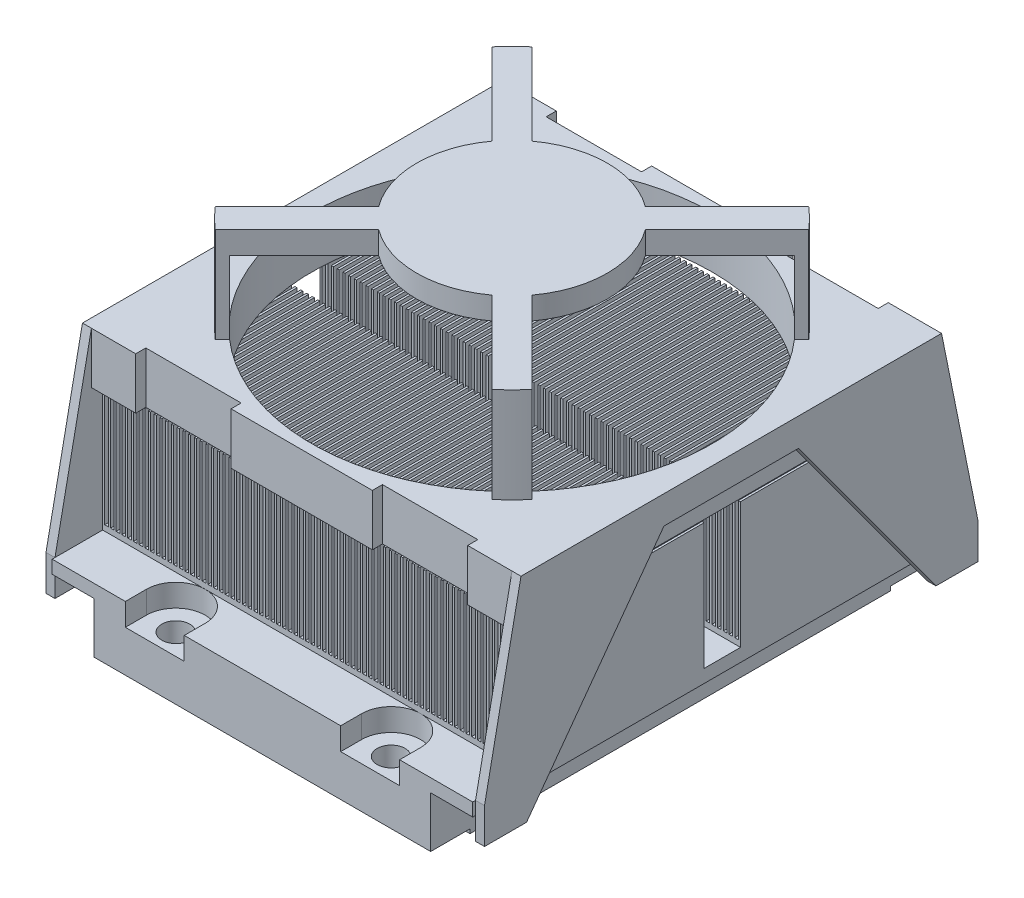
from build123d import *

# Parameters (mm, degrees)
SKETCH1_W                = 75
SKETCH1_H                = 89
BOSS_EXTRUDE1_DEPTH      = 12.15
SKETCH2_W                = 7.5
SKETCH2_H                = 89
CUT_EXTRUDE1_DEPTH       = 9.82
SKETCH3_W                = 60
SKETCH3_H                = 7
CUT_EXTRUDE2_DEPTH       = 0.75
SKETCH4_R                = 2.5
CUT_EXTRUDE3_DEPTH       = 60.299747048
CUT_EXTRUDE4_DEPTH       = 4
SKETCH6_W                = 75
SKETCH6_H                = 32.25
BOSS_EXTRUDE2_DEPTH      = 1
SKETCH7_W                = 0.375
SKETCH7_H                = 32.25
BOSS_EXTRUDE3_DEPTH      = 21.5
LPATTERN2_COUNT          = 74
LPATTERN2_PITCH          = 1.022260274
MIRROR1_COPY_1_SKETCH_W  = 0.375
MIRROR1_COPY_1_SKETCH_H  = 32.25
MIRROR1_COPY_1_DEPTH     = 21.5
MIRROR1_COPY_2_SKETCH_W  = 0.375
MIRROR1_COPY_2_SKETCH_H  = 32.25
MIRROR1_COPY_2_DEPTH     = 21.5
MIRROR1_COPY_3_SKETCH_W  = 0.375
MIRROR1_COPY_3_SKETCH_H  = 32.25
MIRROR1_COPY_3_DEPTH     = 21.5
MIRROR1_COPY_4_SKETCH_W  = 0.375
MIRROR1_COPY_4_SKETCH_H  = 32.25
MIRROR1_COPY_4_DEPTH     = 21.5
MIRROR1_COPY_5_SKETCH_W  = 0.375
MIRROR1_COPY_5_SKETCH_H  = 32.25
MIRROR1_COPY_5_DEPTH     = 21.5
MIRROR1_COPY_6_SKETCH_W  = 0.375
MIRROR1_COPY_6_SKETCH_H  = 32.25
MIRROR1_COPY_6_DEPTH     = 21.5
MIRROR1_COPY_7_SKETCH_W  = 0.375
MIRROR1_COPY_7_SKETCH_H  = 32.25
MIRROR1_COPY_7_DEPTH     = 21.5
MIRROR1_COPY_8_SKETCH_W  = 0.375
MIRROR1_COPY_8_SKETCH_H  = 32.25
MIRROR1_COPY_8_DEPTH     = 21.5
MIRROR1_COPY_9_SKETCH_W  = 0.375
MIRROR1_COPY_9_SKETCH_H  = 32.25
MIRROR1_COPY_9_DEPTH     = 21.5
MIRROR1_COPY_10_SKETCH_W = 0.375
MIRROR1_COPY_10_SKETCH_H = 32.25
MIRROR1_COPY_10_DEPTH    = 21.5
MIRROR1_COPY_11_SKETCH_W = 0.375
MIRROR1_COPY_11_SKETCH_H = 32.25
MIRROR1_COPY_11_DEPTH    = 21.5
MIRROR1_COPY_12_SKETCH_W = 0.375
MIRROR1_COPY_12_SKETCH_H = 32.25
MIRROR1_COPY_12_DEPTH    = 21.5
MIRROR1_COPY_13_SKETCH_W = 0.375
MIRROR1_COPY_13_SKETCH_H = 32.25
MIRROR1_COPY_13_DEPTH    = 21.5
MIRROR1_COPY_14_SKETCH_W = 0.375
MIRROR1_COPY_14_SKETCH_H = 32.25
MIRROR1_COPY_14_DEPTH    = 21.5
MIRROR1_COPY_15_SKETCH_W = 0.375
MIRROR1_COPY_15_SKETCH_H = 32.25
MIRROR1_COPY_15_DEPTH    = 21.5
MIRROR1_COPY_16_SKETCH_W = 0.375
MIRROR1_COPY_16_SKETCH_H = 32.25
MIRROR1_COPY_16_DEPTH    = 21.5
MIRROR1_COPY_17_SKETCH_W = 0.375
MIRROR1_COPY_17_SKETCH_H = 32.25
MIRROR1_COPY_17_DEPTH    = 21.5
MIRROR1_COPY_18_SKETCH_W = 0.375
MIRROR1_COPY_18_SKETCH_H = 32.25
MIRROR1_COPY_18_DEPTH    = 21.5
MIRROR1_COPY_19_SKETCH_W = 0.375
MIRROR1_COPY_19_SKETCH_H = 32.25
MIRROR1_COPY_19_DEPTH    = 21.5
MIRROR1_COPY_20_SKETCH_W = 0.375
MIRROR1_COPY_20_SKETCH_H = 32.25
MIRROR1_COPY_20_DEPTH    = 21.5
MIRROR1_COPY_21_SKETCH_W = 0.375
MIRROR1_COPY_21_SKETCH_H = 32.25
MIRROR1_COPY_21_DEPTH    = 21.5
MIRROR1_COPY_22_SKETCH_W = 0.375
MIRROR1_COPY_22_SKETCH_H = 32.25
MIRROR1_COPY_22_DEPTH    = 21.5
MIRROR1_COPY_23_SKETCH_W = 0.375
MIRROR1_COPY_23_SKETCH_H = 32.25
MIRROR1_COPY_23_DEPTH    = 21.5
MIRROR1_COPY_24_SKETCH_W = 0.375
MIRROR1_COPY_24_SKETCH_H = 32.25
MIRROR1_COPY_24_DEPTH    = 21.5
MIRROR1_COPY_25_SKETCH_W = 0.375
MIRROR1_COPY_25_SKETCH_H = 32.25
MIRROR1_COPY_25_DEPTH    = 21.5
MIRROR1_COPY_26_SKETCH_W = 0.375
MIRROR1_COPY_26_SKETCH_H = 32.25
MIRROR1_COPY_26_DEPTH    = 21.5
MIRROR1_COPY_27_SKETCH_W = 0.375
MIRROR1_COPY_27_SKETCH_H = 32.25
MIRROR1_COPY_27_DEPTH    = 21.5
MIRROR1_COPY_28_SKETCH_W = 0.375
MIRROR1_COPY_28_SKETCH_H = 32.25
MIRROR1_COPY_28_DEPTH    = 21.5
MIRROR1_COPY_29_SKETCH_W = 0.375
MIRROR1_COPY_29_SKETCH_H = 32.25
MIRROR1_COPY_29_DEPTH    = 21.5
MIRROR1_COPY_30_SKETCH_W = 0.375
MIRROR1_COPY_30_SKETCH_H = 32.25
MIRROR1_COPY_30_DEPTH    = 21.5
MIRROR1_COPY_31_SKETCH_W = 0.375
MIRROR1_COPY_31_SKETCH_H = 32.25
MIRROR1_COPY_31_DEPTH    = 21.5
MIRROR1_COPY_32_SKETCH_W = 0.375
MIRROR1_COPY_32_SKETCH_H = 32.25
MIRROR1_COPY_32_DEPTH    = 21.5
MIRROR1_COPY_33_SKETCH_W = 0.375
MIRROR1_COPY_33_SKETCH_H = 32.25
MIRROR1_COPY_33_DEPTH    = 21.5
MIRROR1_COPY_34_SKETCH_W = 0.375
MIRROR1_COPY_34_SKETCH_H = 32.25
MIRROR1_COPY_34_DEPTH    = 21.5
MIRROR1_COPY_35_SKETCH_W = 0.375
MIRROR1_COPY_35_SKETCH_H = 32.25
MIRROR1_COPY_35_DEPTH    = 21.5
MIRROR1_COPY_36_SKETCH_W = 0.375
MIRROR1_COPY_36_SKETCH_H = 32.25
MIRROR1_COPY_36_DEPTH    = 21.5
MIRROR1_COPY_37_SKETCH_W = 0.375
MIRROR1_COPY_37_SKETCH_H = 32.25
MIRROR1_COPY_37_DEPTH    = 21.5
MIRROR1_COPY_38_SKETCH_W = 0.375
MIRROR1_COPY_38_SKETCH_H = 32.25
MIRROR1_COPY_38_DEPTH    = 21.5
MIRROR1_COPY_39_SKETCH_W = 0.375
MIRROR1_COPY_39_SKETCH_H = 32.25
MIRROR1_COPY_39_DEPTH    = 21.5
MIRROR1_COPY_40_SKETCH_W = 0.375
MIRROR1_COPY_40_SKETCH_H = 32.25
MIRROR1_COPY_40_DEPTH    = 21.5
MIRROR1_COPY_41_SKETCH_W = 0.375
MIRROR1_COPY_41_SKETCH_H = 32.25
MIRROR1_COPY_41_DEPTH    = 21.5
MIRROR1_COPY_42_SKETCH_W = 0.375
MIRROR1_COPY_42_SKETCH_H = 32.25
MIRROR1_COPY_42_DEPTH    = 21.5
MIRROR1_COPY_43_SKETCH_W = 0.375
MIRROR1_COPY_43_SKETCH_H = 32.25
MIRROR1_COPY_43_DEPTH    = 21.5
MIRROR1_COPY_44_SKETCH_W = 0.375
MIRROR1_COPY_44_SKETCH_H = 32.25
MIRROR1_COPY_44_DEPTH    = 21.5
MIRROR1_COPY_45_SKETCH_W = 0.375
MIRROR1_COPY_45_SKETCH_H = 32.25
MIRROR1_COPY_45_DEPTH    = 21.5
MIRROR1_COPY_46_SKETCH_W = 0.375
MIRROR1_COPY_46_SKETCH_H = 32.25
MIRROR1_COPY_46_DEPTH    = 21.5
MIRROR1_COPY_47_SKETCH_W = 0.375
MIRROR1_COPY_47_SKETCH_H = 32.25
MIRROR1_COPY_47_DEPTH    = 21.5
MIRROR1_COPY_48_SKETCH_W = 0.375
MIRROR1_COPY_48_SKETCH_H = 32.25
MIRROR1_COPY_48_DEPTH    = 21.5
MIRROR1_COPY_49_SKETCH_W = 0.375
MIRROR1_COPY_49_SKETCH_H = 32.25
MIRROR1_COPY_49_DEPTH    = 21.5
MIRROR1_COPY_50_SKETCH_W = 0.375
MIRROR1_COPY_50_SKETCH_H = 32.25
MIRROR1_COPY_50_DEPTH    = 21.5
MIRROR1_COPY_51_SKETCH_W = 0.375
MIRROR1_COPY_51_SKETCH_H = 32.25
MIRROR1_COPY_51_DEPTH    = 21.5
MIRROR1_COPY_52_SKETCH_W = 0.375
MIRROR1_COPY_52_SKETCH_H = 32.25
MIRROR1_COPY_52_DEPTH    = 21.5
MIRROR1_COPY_53_SKETCH_W = 0.375
MIRROR1_COPY_53_SKETCH_H = 32.25
MIRROR1_COPY_53_DEPTH    = 21.5
MIRROR1_COPY_54_SKETCH_W = 0.375
MIRROR1_COPY_54_SKETCH_H = 32.25
MIRROR1_COPY_54_DEPTH    = 21.5
MIRROR1_COPY_55_SKETCH_W = 0.375
MIRROR1_COPY_55_SKETCH_H = 32.25
MIRROR1_COPY_55_DEPTH    = 21.5
MIRROR1_COPY_56_SKETCH_W = 0.375
MIRROR1_COPY_56_SKETCH_H = 32.25
MIRROR1_COPY_56_DEPTH    = 21.5
MIRROR1_COPY_57_SKETCH_W = 0.375
MIRROR1_COPY_57_SKETCH_H = 32.25
MIRROR1_COPY_57_DEPTH    = 21.5
MIRROR1_COPY_58_SKETCH_W = 0.375
MIRROR1_COPY_58_SKETCH_H = 32.25
MIRROR1_COPY_58_DEPTH    = 21.5
MIRROR1_COPY_59_SKETCH_W = 0.375
MIRROR1_COPY_59_SKETCH_H = 32.25
MIRROR1_COPY_59_DEPTH    = 21.5
MIRROR1_COPY_60_SKETCH_W = 0.375
MIRROR1_COPY_60_SKETCH_H = 32.25
MIRROR1_COPY_60_DEPTH    = 21.5
MIRROR1_COPY_61_SKETCH_W = 0.375
MIRROR1_COPY_61_SKETCH_H = 32.25
MIRROR1_COPY_61_DEPTH    = 21.5
MIRROR1_COPY_62_SKETCH_W = 0.375
MIRROR1_COPY_62_SKETCH_H = 32.25
MIRROR1_COPY_62_DEPTH    = 21.5
MIRROR1_COPY_63_SKETCH_W = 0.375
MIRROR1_COPY_63_SKETCH_H = 32.25
MIRROR1_COPY_63_DEPTH    = 21.5
MIRROR1_COPY_64_SKETCH_W = 0.375
MIRROR1_COPY_64_SKETCH_H = 32.25
MIRROR1_COPY_64_DEPTH    = 21.5
MIRROR1_COPY_65_SKETCH_W = 0.375
MIRROR1_COPY_65_SKETCH_H = 32.25
MIRROR1_COPY_65_DEPTH    = 21.5
MIRROR1_COPY_66_SKETCH_W = 0.375
MIRROR1_COPY_66_SKETCH_H = 32.25
MIRROR1_COPY_66_DEPTH    = 21.5
MIRROR1_COPY_67_SKETCH_W = 0.375
MIRROR1_COPY_67_SKETCH_H = 32.25
MIRROR1_COPY_67_DEPTH    = 21.5
MIRROR1_COPY_68_SKETCH_W = 0.375
MIRROR1_COPY_68_SKETCH_H = 32.25
MIRROR1_COPY_68_DEPTH    = 21.5
MIRROR1_COPY_69_SKETCH_W = 0.375
MIRROR1_COPY_69_SKETCH_H = 32.25
MIRROR1_COPY_69_DEPTH    = 21.5
MIRROR1_COPY_70_SKETCH_W = 0.375
MIRROR1_COPY_70_SKETCH_H = 32.25
MIRROR1_COPY_70_DEPTH    = 21.5
MIRROR1_COPY_71_SKETCH_W = 0.375
MIRROR1_COPY_71_SKETCH_H = 32.25
MIRROR1_COPY_71_DEPTH    = 21.5
MIRROR1_COPY_72_SKETCH_W = 0.375
MIRROR1_COPY_72_SKETCH_H = 32.25
MIRROR1_COPY_72_DEPTH    = 21.5
MIRROR1_COPY_73_SKETCH_W = 0.375
MIRROR1_COPY_73_SKETCH_H = 32.25
MIRROR1_COPY_73_DEPTH    = 21.5
BOSS_EXTRUDE4_DEPTH      = 1.6
BOSS_EXTRUDE5_DEPTH      = 9.17
SKETCH10_R               = 37.5
BOSS_EXTRUDE6_DEPTH      = 17
SKETCH11_R               = 35.7
CUT_EXTRUDE5_DEPTH       = 22.17
CUT_EXTRUDE6_START       = -17
CUT_EXTRUDE6_DEPTH       = 17


with BuildPart() as part:
    # Sketch1 → Boss-Extrude1 (new body)
    with BuildSketch(Plane(origin=(0, 0, 0), x_dir=(1, 0, 0), z_dir=(0, 1, 0))):
        Rectangle(SKETCH1_W, SKETCH1_H)
    extrude(amount=BOSS_EXTRUDE1_DEPTH)

    # Sketch2 → Cut-Extrude1 (cut)
    with BuildSketch(Plane.XZ):
        with Locations((-33.75, 0)):
            Rectangle(SKETCH2_W, SKETCH2_H)
        with Locations((33.75, 0)):
            Rectangle(SKETCH2_W, SKETCH2_H)
    extrude(amount=-CUT_EXTRUDE1_DEPTH, mode=Mode.SUBTRACT)

    # Sketch3 → Cut-Extrude2 (cut)
    with BuildSketch(Plane.XZ):
        with Locations((0, 41)):
            Rectangle(SKETCH3_W, SKETCH3_H)
        with Locations((0, -41)):
            Rectangle(SKETCH3_W, SKETCH3_H)
    extrude(amount=-CUT_EXTRUDE2_DEPTH, mode=Mode.SUBTRACT)

    # Sketch4 → Cut-Extrude3 (cut, through all)
    with BuildSketch(Plane.XZ.offset(-0.75)):
        with Locations(Location((-19.2, 40.75, 0), (0, 0, 270))):
            Circle(SKETCH4_R)
        with Locations(Location((19.2, 40.75, 0), (0, 0, 270))):
            Circle(SKETCH4_R)
        with Locations(Location((19.2, -40.75, 0), (0, 0, 90))):
            Circle(SKETCH4_R)
        with Locations(Location((-19.2, -40.75, 0), (0, 0, 90))):
            Circle(SKETCH4_R)
    extrude(amount=-CUT_EXTRUDE3_DEPTH, mode=Mode.SUBTRACT)

    # Sketch5 → Cut-Extrude4 (cut)
    with BuildSketch(Plane(origin=(0, 12.15, 0), x_dir=(1, 0, 0), z_dir=(0, 1, 0))):
        with BuildLine():
            Line((-24.45, 40.75), (-24.45, 44.5))
            Line((-24.45, 44.5), (-13.95, 44.5))
            Line((-13.95, 44.5), (-13.95, 40.75))
            ThreePointArc((-13.95, 40.75), (-19.2, 35.5), (-24.45, 40.75))
        make_face()
        with BuildLine():
            Line((24.45, 40.75), (24.45, 44.5))
            Line((24.45, 44.5), (13.95, 44.5))
            Line((13.95, 44.5), (13.95, 40.75))
            ThreePointArc((13.95, 40.75), (19.2, 35.5), (24.45, 40.75))
        make_face()
        with BuildLine():
            Line((13.95, -40.75), (13.95, -44.5))
            Line((13.95, -44.5), (24.45, -44.5))
            Line((24.45, -44.5), (24.45, -40.75))
            ThreePointArc((24.45, -40.75), (19.2, -35.5), (13.95, -40.75))
        make_face()
        with BuildLine():
            Line((-24.45, -40.75), (-24.45, -44.5))
            Line((-24.45, -44.5), (-13.95, -44.5))
            Line((-13.95, -44.5), (-13.95, -40.75))
            ThreePointArc((-13.95, -40.75), (-19.2, -35.5), (-24.45, -40.75))
        make_face()
    extrude(amount=-CUT_EXTRUDE4_DEPTH, mode=Mode.SUBTRACT)

    # Sketch6 → Boss-Extrude2 (add)
    with BuildSketch(Plane(origin=(0, 12.15, 0), x_dir=(1, 0, 0), z_dir=(0, 1, 0))):
        with Locations((0, 19.375)):
            Rectangle(SKETCH6_W, SKETCH6_H)
    boss_extrude2 = extrude(amount=BOSS_EXTRUDE2_DEPTH)

    # Sketch7 → Boss-Extrude3 (add)
    with BuildSketch(Plane(origin=(0, 13.15, 0), x_dir=(1, 0, 0), z_dir=(0, 1, 0))):
        with Locations((-37.3125, 19.375)):
            Rectangle(SKETCH7_W, SKETCH7_H)
    boss_extrude3 = extrude(amount=BOSS_EXTRUDE3_DEPTH)

    # LPattern2: Boss-Extrude3 ×74
    with Locations(*[(i * LPATTERN2_PITCH, 0, 0) for i in range(1, LPATTERN2_COUNT)]):
        add(boss_extrude3)

    # Mirror1: Boss-Extrude2, Boss-Extrude3 across plane
    add(boss_extrude2.mirror(Plane(origin=(0, 0, 0), x_dir=(1, 0, 0), z_dir=(0, 0, -1))))
    add(boss_extrude3.mirror(Plane(origin=(0, 0, 0), x_dir=(1, 0, 0), z_dir=(0, 0, -1))))

    # Mirror1 copy 1 sketch → Mirror1 copy 1 (add)
    with BuildSketch(Plane(origin=(1.022260274, 13.15, 0), x_dir=(1, 0, 0), z_dir=(0, 1, 0))):
        with Locations((-37.3125, -19.375)):
            Rectangle(MIRROR1_COPY_1_SKETCH_W, MIRROR1_COPY_1_SKETCH_H)
    extrude(amount=MIRROR1_COPY_1_DEPTH)

    # Mirror1 copy 2 sketch → Mirror1 copy 2 (add)
    with BuildSketch(Plane(origin=(2.044520548, 13.15, 0), x_dir=(1, 0, 0), z_dir=(0, 1, 0))):
        with Locations((-37.3125, -19.375)):
            Rectangle(MIRROR1_COPY_2_SKETCH_W, MIRROR1_COPY_2_SKETCH_H)
    extrude(amount=MIRROR1_COPY_2_DEPTH)

    # Mirror1 copy 3 sketch → Mirror1 copy 3 (add)
    with BuildSketch(Plane(origin=(3.066780822, 13.15, 0), x_dir=(1, 0, 0), z_dir=(0, 1, 0))):
        with Locations((-37.3125, -19.375)):
            Rectangle(MIRROR1_COPY_3_SKETCH_W, MIRROR1_COPY_3_SKETCH_H)
    extrude(amount=MIRROR1_COPY_3_DEPTH)

    # Mirror1 copy 4 sketch → Mirror1 copy 4 (add)
    with BuildSketch(Plane(origin=(4.089041096, 13.15, 0), x_dir=(1, 0, 0), z_dir=(0, 1, 0))):
        with Locations((-37.3125, -19.375)):
            Rectangle(MIRROR1_COPY_4_SKETCH_W, MIRROR1_COPY_4_SKETCH_H)
    extrude(amount=MIRROR1_COPY_4_DEPTH)

    # Mirror1 copy 5 sketch → Mirror1 copy 5 (add)
    with BuildSketch(Plane(origin=(5.11130137, 13.15, 0), x_dir=(1, 0, 0), z_dir=(0, 1, 0))):
        with Locations((-37.3125, -19.375)):
            Rectangle(MIRROR1_COPY_5_SKETCH_W, MIRROR1_COPY_5_SKETCH_H)
    extrude(amount=MIRROR1_COPY_5_DEPTH)

    # Mirror1 copy 6 sketch → Mirror1 copy 6 (add)
    with BuildSketch(Plane(origin=(6.133561644, 13.15, 0), x_dir=(1, 0, 0), z_dir=(0, 1, 0))):
        with Locations((-37.3125, -19.375)):
            Rectangle(MIRROR1_COPY_6_SKETCH_W, MIRROR1_COPY_6_SKETCH_H)
    extrude(amount=MIRROR1_COPY_6_DEPTH)

    # Mirror1 copy 7 sketch → Mirror1 copy 7 (add)
    with BuildSketch(Plane(origin=(7.155821918, 13.15, 0), x_dir=(1, 0, 0), z_dir=(0, 1, 0))):
        with Locations((-37.3125, -19.375)):
            Rectangle(MIRROR1_COPY_7_SKETCH_W, MIRROR1_COPY_7_SKETCH_H)
    extrude(amount=MIRROR1_COPY_7_DEPTH)

    # Mirror1 copy 8 sketch → Mirror1 copy 8 (add)
    with BuildSketch(Plane(origin=(8.178082192, 13.15, 0), x_dir=(1, 0, 0), z_dir=(0, 1, 0))):
        with Locations((-37.3125, -19.375)):
            Rectangle(MIRROR1_COPY_8_SKETCH_W, MIRROR1_COPY_8_SKETCH_H)
    extrude(amount=MIRROR1_COPY_8_DEPTH)

    # Mirror1 copy 9 sketch → Mirror1 copy 9 (add)
    with BuildSketch(Plane(origin=(9.200342466, 13.15, 0), x_dir=(1, 0, 0), z_dir=(0, 1, 0))):
        with Locations((-37.3125, -19.375)):
            Rectangle(MIRROR1_COPY_9_SKETCH_W, MIRROR1_COPY_9_SKETCH_H)
    extrude(amount=MIRROR1_COPY_9_DEPTH)

    # Mirror1 copy 10 sketch → Mirror1 copy 10 (add)
    with BuildSketch(Plane(origin=(10.22260274, 13.15, 0), x_dir=(1, 0, 0), z_dir=(0, 1, 0))):
        with Locations((-37.3125, -19.375)):
            Rectangle(MIRROR1_COPY_10_SKETCH_W, MIRROR1_COPY_10_SKETCH_H)
    extrude(amount=MIRROR1_COPY_10_DEPTH)

    # Mirror1 copy 11 sketch → Mirror1 copy 11 (add)
    with BuildSketch(Plane(origin=(11.244863014, 13.15, 0), x_dir=(1, 0, 0), z_dir=(0, 1, 0))):
        with Locations((-37.3125, -19.375)):
            Rectangle(MIRROR1_COPY_11_SKETCH_W, MIRROR1_COPY_11_SKETCH_H)
    extrude(amount=MIRROR1_COPY_11_DEPTH)

    # Mirror1 copy 12 sketch → Mirror1 copy 12 (add)
    with BuildSketch(Plane(origin=(12.267123288, 13.15, 0), x_dir=(1, 0, 0), z_dir=(0, 1, 0))):
        with Locations((-37.3125, -19.375)):
            Rectangle(MIRROR1_COPY_12_SKETCH_W, MIRROR1_COPY_12_SKETCH_H)
    extrude(amount=MIRROR1_COPY_12_DEPTH)

    # Mirror1 copy 13 sketch → Mirror1 copy 13 (add)
    with BuildSketch(Plane(origin=(13.289383562, 13.15, 0), x_dir=(1, 0, 0), z_dir=(0, 1, 0))):
        with Locations((-37.3125, -19.375)):
            Rectangle(MIRROR1_COPY_13_SKETCH_W, MIRROR1_COPY_13_SKETCH_H)
    extrude(amount=MIRROR1_COPY_13_DEPTH)

    # Mirror1 copy 14 sketch → Mirror1 copy 14 (add)
    with BuildSketch(Plane(origin=(14.311643836, 13.15, 0), x_dir=(1, 0, 0), z_dir=(0, 1, 0))):
        with Locations((-37.3125, -19.375)):
            Rectangle(MIRROR1_COPY_14_SKETCH_W, MIRROR1_COPY_14_SKETCH_H)
    extrude(amount=MIRROR1_COPY_14_DEPTH)

    # Mirror1 copy 15 sketch → Mirror1 copy 15 (add)
    with BuildSketch(Plane(origin=(15.33390411, 13.15, 0), x_dir=(1, 0, 0), z_dir=(0, 1, 0))):
        with Locations((-37.3125, -19.375)):
            Rectangle(MIRROR1_COPY_15_SKETCH_W, MIRROR1_COPY_15_SKETCH_H)
    extrude(amount=MIRROR1_COPY_15_DEPTH)

    # Mirror1 copy 16 sketch → Mirror1 copy 16 (add)
    with BuildSketch(Plane(origin=(16.356164384, 13.15, 0), x_dir=(1, 0, 0), z_dir=(0, 1, 0))):
        with Locations((-37.3125, -19.375)):
            Rectangle(MIRROR1_COPY_16_SKETCH_W, MIRROR1_COPY_16_SKETCH_H)
    extrude(amount=MIRROR1_COPY_16_DEPTH)

    # Mirror1 copy 17 sketch → Mirror1 copy 17 (add)
    with BuildSketch(Plane(origin=(17.378424658, 13.15, 0), x_dir=(1, 0, 0), z_dir=(0, 1, 0))):
        with Locations((-37.3125, -19.375)):
            Rectangle(MIRROR1_COPY_17_SKETCH_W, MIRROR1_COPY_17_SKETCH_H)
    extrude(amount=MIRROR1_COPY_17_DEPTH)

    # Mirror1 copy 18 sketch → Mirror1 copy 18 (add)
    with BuildSketch(Plane(origin=(18.400684932, 13.15, 0), x_dir=(1, 0, 0), z_dir=(0, 1, 0))):
        with Locations((-37.3125, -19.375)):
            Rectangle(MIRROR1_COPY_18_SKETCH_W, MIRROR1_COPY_18_SKETCH_H)
    extrude(amount=MIRROR1_COPY_18_DEPTH)

    # Mirror1 copy 19 sketch → Mirror1 copy 19 (add)
    with BuildSketch(Plane(origin=(19.422945205, 13.15, 0), x_dir=(1, 0, 0), z_dir=(0, 1, 0))):
        with Locations((-37.3125, -19.375)):
            Rectangle(MIRROR1_COPY_19_SKETCH_W, MIRROR1_COPY_19_SKETCH_H)
    extrude(amount=MIRROR1_COPY_19_DEPTH)

    # Mirror1 copy 20 sketch → Mirror1 copy 20 (add)
    with BuildSketch(Plane(origin=(20.445205479, 13.15, 0), x_dir=(1, 0, 0), z_dir=(0, 1, 0))):
        with Locations((-37.3125, -19.375)):
            Rectangle(MIRROR1_COPY_20_SKETCH_W, MIRROR1_COPY_20_SKETCH_H)
    extrude(amount=MIRROR1_COPY_20_DEPTH)

    # Mirror1 copy 21 sketch → Mirror1 copy 21 (add)
    with BuildSketch(Plane(origin=(21.467465753, 13.15, 0), x_dir=(1, 0, 0), z_dir=(0, 1, 0))):
        with Locations((-37.3125, -19.375)):
            Rectangle(MIRROR1_COPY_21_SKETCH_W, MIRROR1_COPY_21_SKETCH_H)
    extrude(amount=MIRROR1_COPY_21_DEPTH)

    # Mirror1 copy 22 sketch → Mirror1 copy 22 (add)
    with BuildSketch(Plane(origin=(22.489726027, 13.15, 0), x_dir=(1, 0, 0), z_dir=(0, 1, 0))):
        with Locations((-37.3125, -19.375)):
            Rectangle(MIRROR1_COPY_22_SKETCH_W, MIRROR1_COPY_22_SKETCH_H)
    extrude(amount=MIRROR1_COPY_22_DEPTH)

    # Mirror1 copy 23 sketch → Mirror1 copy 23 (add)
    with BuildSketch(Plane(origin=(23.511986301, 13.15, 0), x_dir=(1, 0, 0), z_dir=(0, 1, 0))):
        with Locations((-37.3125, -19.375)):
            Rectangle(MIRROR1_COPY_23_SKETCH_W, MIRROR1_COPY_23_SKETCH_H)
    extrude(amount=MIRROR1_COPY_23_DEPTH)

    # Mirror1 copy 24 sketch → Mirror1 copy 24 (add)
    with BuildSketch(Plane(origin=(24.534246575, 13.15, 0), x_dir=(1, 0, 0), z_dir=(0, 1, 0))):
        with Locations((-37.3125, -19.375)):
            Rectangle(MIRROR1_COPY_24_SKETCH_W, MIRROR1_COPY_24_SKETCH_H)
    extrude(amount=MIRROR1_COPY_24_DEPTH)

    # Mirror1 copy 25 sketch → Mirror1 copy 25 (add)
    with BuildSketch(Plane(origin=(25.556506849, 13.15, 0), x_dir=(1, 0, 0), z_dir=(0, 1, 0))):
        with Locations((-37.3125, -19.375)):
            Rectangle(MIRROR1_COPY_25_SKETCH_W, MIRROR1_COPY_25_SKETCH_H)
    extrude(amount=MIRROR1_COPY_25_DEPTH)

    # Mirror1 copy 26 sketch → Mirror1 copy 26 (add)
    with BuildSketch(Plane(origin=(26.578767123, 13.15, 0), x_dir=(1, 0, 0), z_dir=(0, 1, 0))):
        with Locations((-37.3125, -19.375)):
            Rectangle(MIRROR1_COPY_26_SKETCH_W, MIRROR1_COPY_26_SKETCH_H)
    extrude(amount=MIRROR1_COPY_26_DEPTH)

    # Mirror1 copy 27 sketch → Mirror1 copy 27 (add)
    with BuildSketch(Plane(origin=(27.601027397, 13.15, 0), x_dir=(1, 0, 0), z_dir=(0, 1, 0))):
        with Locations((-37.3125, -19.375)):
            Rectangle(MIRROR1_COPY_27_SKETCH_W, MIRROR1_COPY_27_SKETCH_H)
    extrude(amount=MIRROR1_COPY_27_DEPTH)

    # Mirror1 copy 28 sketch → Mirror1 copy 28 (add)
    with BuildSketch(Plane(origin=(28.623287671, 13.15, 0), x_dir=(1, 0, 0), z_dir=(0, 1, 0))):
        with Locations((-37.3125, -19.375)):
            Rectangle(MIRROR1_COPY_28_SKETCH_W, MIRROR1_COPY_28_SKETCH_H)
    extrude(amount=MIRROR1_COPY_28_DEPTH)

    # Mirror1 copy 29 sketch → Mirror1 copy 29 (add)
    with BuildSketch(Plane(origin=(29.645547945, 13.15, 0), x_dir=(1, 0, 0), z_dir=(0, 1, 0))):
        with Locations((-37.3125, -19.375)):
            Rectangle(MIRROR1_COPY_29_SKETCH_W, MIRROR1_COPY_29_SKETCH_H)
    extrude(amount=MIRROR1_COPY_29_DEPTH)

    # Mirror1 copy 30 sketch → Mirror1 copy 30 (add)
    with BuildSketch(Plane(origin=(30.667808219, 13.15, 0), x_dir=(1, 0, 0), z_dir=(0, 1, 0))):
        with Locations((-37.3125, -19.375)):
            Rectangle(MIRROR1_COPY_30_SKETCH_W, MIRROR1_COPY_30_SKETCH_H)
    extrude(amount=MIRROR1_COPY_30_DEPTH)

    # Mirror1 copy 31 sketch → Mirror1 copy 31 (add)
    with BuildSketch(Plane(origin=(31.690068493, 13.15, 0), x_dir=(1, 0, 0), z_dir=(0, 1, 0))):
        with Locations((-37.3125, -19.375)):
            Rectangle(MIRROR1_COPY_31_SKETCH_W, MIRROR1_COPY_31_SKETCH_H)
    extrude(amount=MIRROR1_COPY_31_DEPTH)

    # Mirror1 copy 32 sketch → Mirror1 copy 32 (add)
    with BuildSketch(Plane(origin=(32.712328767, 13.15, 0), x_dir=(1, 0, 0), z_dir=(0, 1, 0))):
        with Locations((-37.3125, -19.375)):
            Rectangle(MIRROR1_COPY_32_SKETCH_W, MIRROR1_COPY_32_SKETCH_H)
    extrude(amount=MIRROR1_COPY_32_DEPTH)

    # Mirror1 copy 33 sketch → Mirror1 copy 33 (add)
    with BuildSketch(Plane(origin=(33.734589041, 13.15, 0), x_dir=(1, 0, 0), z_dir=(0, 1, 0))):
        with Locations((-37.3125, -19.375)):
            Rectangle(MIRROR1_COPY_33_SKETCH_W, MIRROR1_COPY_33_SKETCH_H)
    extrude(amount=MIRROR1_COPY_33_DEPTH)

    # Mirror1 copy 34 sketch → Mirror1 copy 34 (add)
    with BuildSketch(Plane(origin=(34.756849315, 13.15, 0), x_dir=(1, 0, 0), z_dir=(0, 1, 0))):
        with Locations((-37.3125, -19.375)):
            Rectangle(MIRROR1_COPY_34_SKETCH_W, MIRROR1_COPY_34_SKETCH_H)
    extrude(amount=MIRROR1_COPY_34_DEPTH)

    # Mirror1 copy 35 sketch → Mirror1 copy 35 (add)
    with BuildSketch(Plane(origin=(35.779109589, 13.15, 0), x_dir=(1, 0, 0), z_dir=(0, 1, 0))):
        with Locations((-37.3125, -19.375)):
            Rectangle(MIRROR1_COPY_35_SKETCH_W, MIRROR1_COPY_35_SKETCH_H)
    extrude(amount=MIRROR1_COPY_35_DEPTH)

    # Mirror1 copy 36 sketch → Mirror1 copy 36 (add)
    with BuildSketch(Plane(origin=(36.801369863, 13.15, 0), x_dir=(1, 0, 0), z_dir=(0, 1, 0))):
        with Locations((-37.3125, -19.375)):
            Rectangle(MIRROR1_COPY_36_SKETCH_W, MIRROR1_COPY_36_SKETCH_H)
    extrude(amount=MIRROR1_COPY_36_DEPTH)

    # Mirror1 copy 37 sketch → Mirror1 copy 37 (add)
    with BuildSketch(Plane(origin=(37.823630137, 13.15, 0), x_dir=(1, 0, 0), z_dir=(0, 1, 0))):
        with Locations((-37.3125, -19.375)):
            Rectangle(MIRROR1_COPY_37_SKETCH_W, MIRROR1_COPY_37_SKETCH_H)
    extrude(amount=MIRROR1_COPY_37_DEPTH)

    # Mirror1 copy 38 sketch → Mirror1 copy 38 (add)
    with BuildSketch(Plane(origin=(38.845890411, 13.15, 0), x_dir=(1, 0, 0), z_dir=(0, 1, 0))):
        with Locations((-37.3125, -19.375)):
            Rectangle(MIRROR1_COPY_38_SKETCH_W, MIRROR1_COPY_38_SKETCH_H)
    extrude(amount=MIRROR1_COPY_38_DEPTH)

    # Mirror1 copy 39 sketch → Mirror1 copy 39 (add)
    with BuildSketch(Plane(origin=(39.868150685, 13.15, 0), x_dir=(1, 0, 0), z_dir=(0, 1, 0))):
        with Locations((-37.3125, -19.375)):
            Rectangle(MIRROR1_COPY_39_SKETCH_W, MIRROR1_COPY_39_SKETCH_H)
    extrude(amount=MIRROR1_COPY_39_DEPTH)

    # Mirror1 copy 40 sketch → Mirror1 copy 40 (add)
    with BuildSketch(Plane(origin=(40.890410959, 13.15, 0), x_dir=(1, 0, 0), z_dir=(0, 1, 0))):
        with Locations((-37.3125, -19.375)):
            Rectangle(MIRROR1_COPY_40_SKETCH_W, MIRROR1_COPY_40_SKETCH_H)
    extrude(amount=MIRROR1_COPY_40_DEPTH)

    # Mirror1 copy 41 sketch → Mirror1 copy 41 (add)
    with BuildSketch(Plane(origin=(41.912671233, 13.15, 0), x_dir=(1, 0, 0), z_dir=(0, 1, 0))):
        with Locations((-37.3125, -19.375)):
            Rectangle(MIRROR1_COPY_41_SKETCH_W, MIRROR1_COPY_41_SKETCH_H)
    extrude(amount=MIRROR1_COPY_41_DEPTH)

    # Mirror1 copy 42 sketch → Mirror1 copy 42 (add)
    with BuildSketch(Plane(origin=(42.934931507, 13.15, 0), x_dir=(1, 0, 0), z_dir=(0, 1, 0))):
        with Locations((-37.3125, -19.375)):
            Rectangle(MIRROR1_COPY_42_SKETCH_W, MIRROR1_COPY_42_SKETCH_H)
    extrude(amount=MIRROR1_COPY_42_DEPTH)

    # Mirror1 copy 43 sketch → Mirror1 copy 43 (add)
    with BuildSketch(Plane(origin=(43.957191781, 13.15, 0), x_dir=(1, 0, 0), z_dir=(0, 1, 0))):
        with Locations((-37.3125, -19.375)):
            Rectangle(MIRROR1_COPY_43_SKETCH_W, MIRROR1_COPY_43_SKETCH_H)
    extrude(amount=MIRROR1_COPY_43_DEPTH)

    # Mirror1 copy 44 sketch → Mirror1 copy 44 (add)
    with BuildSketch(Plane(origin=(44.979452055, 13.15, 0), x_dir=(1, 0, 0), z_dir=(0, 1, 0))):
        with Locations((-37.3125, -19.375)):
            Rectangle(MIRROR1_COPY_44_SKETCH_W, MIRROR1_COPY_44_SKETCH_H)
    extrude(amount=MIRROR1_COPY_44_DEPTH)

    # Mirror1 copy 45 sketch → Mirror1 copy 45 (add)
    with BuildSketch(Plane(origin=(46.001712329, 13.15, 0), x_dir=(1, 0, 0), z_dir=(0, 1, 0))):
        with Locations((-37.3125, -19.375)):
            Rectangle(MIRROR1_COPY_45_SKETCH_W, MIRROR1_COPY_45_SKETCH_H)
    extrude(amount=MIRROR1_COPY_45_DEPTH)

    # Mirror1 copy 46 sketch → Mirror1 copy 46 (add)
    with BuildSketch(Plane(origin=(47.023972603, 13.15, 0), x_dir=(1, 0, 0), z_dir=(0, 1, 0))):
        with Locations((-37.3125, -19.375)):
            Rectangle(MIRROR1_COPY_46_SKETCH_W, MIRROR1_COPY_46_SKETCH_H)
    extrude(amount=MIRROR1_COPY_46_DEPTH)

    # Mirror1 copy 47 sketch → Mirror1 copy 47 (add)
    with BuildSketch(Plane(origin=(48.046232877, 13.15, 0), x_dir=(1, 0, 0), z_dir=(0, 1, 0))):
        with Locations((-37.3125, -19.375)):
            Rectangle(MIRROR1_COPY_47_SKETCH_W, MIRROR1_COPY_47_SKETCH_H)
    extrude(amount=MIRROR1_COPY_47_DEPTH)

    # Mirror1 copy 48 sketch → Mirror1 copy 48 (add)
    with BuildSketch(Plane(origin=(49.068493151, 13.15, 0), x_dir=(1, 0, 0), z_dir=(0, 1, 0))):
        with Locations((-37.3125, -19.375)):
            Rectangle(MIRROR1_COPY_48_SKETCH_W, MIRROR1_COPY_48_SKETCH_H)
    extrude(amount=MIRROR1_COPY_48_DEPTH)

    # Mirror1 copy 49 sketch → Mirror1 copy 49 (add)
    with BuildSketch(Plane(origin=(50.090753425, 13.15, 0), x_dir=(1, 0, 0), z_dir=(0, 1, 0))):
        with Locations((-37.3125, -19.375)):
            Rectangle(MIRROR1_COPY_49_SKETCH_W, MIRROR1_COPY_49_SKETCH_H)
    extrude(amount=MIRROR1_COPY_49_DEPTH)

    # Mirror1 copy 50 sketch → Mirror1 copy 50 (add)
    with BuildSketch(Plane(origin=(51.113013699, 13.15, 0), x_dir=(1, 0, 0), z_dir=(0, 1, 0))):
        with Locations((-37.3125, -19.375)):
            Rectangle(MIRROR1_COPY_50_SKETCH_W, MIRROR1_COPY_50_SKETCH_H)
    extrude(amount=MIRROR1_COPY_50_DEPTH)

    # Mirror1 copy 51 sketch → Mirror1 copy 51 (add)
    with BuildSketch(Plane(origin=(52.135273973, 13.15, 0), x_dir=(1, 0, 0), z_dir=(0, 1, 0))):
        with Locations((-37.3125, -19.375)):
            Rectangle(MIRROR1_COPY_51_SKETCH_W, MIRROR1_COPY_51_SKETCH_H)
    extrude(amount=MIRROR1_COPY_51_DEPTH)

    # Mirror1 copy 52 sketch → Mirror1 copy 52 (add)
    with BuildSketch(Plane(origin=(53.157534247, 13.15, 0), x_dir=(1, 0, 0), z_dir=(0, 1, 0))):
        with Locations((-37.3125, -19.375)):
            Rectangle(MIRROR1_COPY_52_SKETCH_W, MIRROR1_COPY_52_SKETCH_H)
    extrude(amount=MIRROR1_COPY_52_DEPTH)

    # Mirror1 copy 53 sketch → Mirror1 copy 53 (add)
    with BuildSketch(Plane(origin=(54.179794521, 13.15, 0), x_dir=(1, 0, 0), z_dir=(0, 1, 0))):
        with Locations((-37.3125, -19.375)):
            Rectangle(MIRROR1_COPY_53_SKETCH_W, MIRROR1_COPY_53_SKETCH_H)
    extrude(amount=MIRROR1_COPY_53_DEPTH)

    # Mirror1 copy 54 sketch → Mirror1 copy 54 (add)
    with BuildSketch(Plane(origin=(55.202054795, 13.15, 0), x_dir=(1, 0, 0), z_dir=(0, 1, 0))):
        with Locations((-37.3125, -19.375)):
            Rectangle(MIRROR1_COPY_54_SKETCH_W, MIRROR1_COPY_54_SKETCH_H)
    extrude(amount=MIRROR1_COPY_54_DEPTH)

    # Mirror1 copy 55 sketch → Mirror1 copy 55 (add)
    with BuildSketch(Plane(origin=(56.224315068, 13.15, 0), x_dir=(1, 0, 0), z_dir=(0, 1, 0))):
        with Locations((-37.3125, -19.375)):
            Rectangle(MIRROR1_COPY_55_SKETCH_W, MIRROR1_COPY_55_SKETCH_H)
    extrude(amount=MIRROR1_COPY_55_DEPTH)

    # Mirror1 copy 56 sketch → Mirror1 copy 56 (add)
    with BuildSketch(Plane(origin=(57.246575342, 13.15, 0), x_dir=(1, 0, 0), z_dir=(0, 1, 0))):
        with Locations((-37.3125, -19.375)):
            Rectangle(MIRROR1_COPY_56_SKETCH_W, MIRROR1_COPY_56_SKETCH_H)
    extrude(amount=MIRROR1_COPY_56_DEPTH)

    # Mirror1 copy 57 sketch → Mirror1 copy 57 (add)
    with BuildSketch(Plane(origin=(58.268835616, 13.15, 0), x_dir=(1, 0, 0), z_dir=(0, 1, 0))):
        with Locations((-37.3125, -19.375)):
            Rectangle(MIRROR1_COPY_57_SKETCH_W, MIRROR1_COPY_57_SKETCH_H)
    extrude(amount=MIRROR1_COPY_57_DEPTH)

    # Mirror1 copy 58 sketch → Mirror1 copy 58 (add)
    with BuildSketch(Plane(origin=(59.29109589, 13.15, 0), x_dir=(1, 0, 0), z_dir=(0, 1, 0))):
        with Locations((-37.3125, -19.375)):
            Rectangle(MIRROR1_COPY_58_SKETCH_W, MIRROR1_COPY_58_SKETCH_H)
    extrude(amount=MIRROR1_COPY_58_DEPTH)

    # Mirror1 copy 59 sketch → Mirror1 copy 59 (add)
    with BuildSketch(Plane(origin=(60.313356164, 13.15, 0), x_dir=(1, 0, 0), z_dir=(0, 1, 0))):
        with Locations((-37.3125, -19.375)):
            Rectangle(MIRROR1_COPY_59_SKETCH_W, MIRROR1_COPY_59_SKETCH_H)
    extrude(amount=MIRROR1_COPY_59_DEPTH)

    # Mirror1 copy 60 sketch → Mirror1 copy 60 (add)
    with BuildSketch(Plane(origin=(61.335616438, 13.15, 0), x_dir=(1, 0, 0), z_dir=(0, 1, 0))):
        with Locations((-37.3125, -19.375)):
            Rectangle(MIRROR1_COPY_60_SKETCH_W, MIRROR1_COPY_60_SKETCH_H)
    extrude(amount=MIRROR1_COPY_60_DEPTH)

    # Mirror1 copy 61 sketch → Mirror1 copy 61 (add)
    with BuildSketch(Plane(origin=(62.357876712, 13.15, 0), x_dir=(1, 0, 0), z_dir=(0, 1, 0))):
        with Locations((-37.3125, -19.375)):
            Rectangle(MIRROR1_COPY_61_SKETCH_W, MIRROR1_COPY_61_SKETCH_H)
    extrude(amount=MIRROR1_COPY_61_DEPTH)

    # Mirror1 copy 62 sketch → Mirror1 copy 62 (add)
    with BuildSketch(Plane(origin=(63.380136986, 13.15, 0), x_dir=(1, 0, 0), z_dir=(0, 1, 0))):
        with Locations((-37.3125, -19.375)):
            Rectangle(MIRROR1_COPY_62_SKETCH_W, MIRROR1_COPY_62_SKETCH_H)
    extrude(amount=MIRROR1_COPY_62_DEPTH)

    # Mirror1 copy 63 sketch → Mirror1 copy 63 (add)
    with BuildSketch(Plane(origin=(64.40239726, 13.15, 0), x_dir=(1, 0, 0), z_dir=(0, 1, 0))):
        with Locations((-37.3125, -19.375)):
            Rectangle(MIRROR1_COPY_63_SKETCH_W, MIRROR1_COPY_63_SKETCH_H)
    extrude(amount=MIRROR1_COPY_63_DEPTH)

    # Mirror1 copy 64 sketch → Mirror1 copy 64 (add)
    with BuildSketch(Plane(origin=(65.424657534, 13.15, 0), x_dir=(1, 0, 0), z_dir=(0, 1, 0))):
        with Locations((-37.3125, -19.375)):
            Rectangle(MIRROR1_COPY_64_SKETCH_W, MIRROR1_COPY_64_SKETCH_H)
    extrude(amount=MIRROR1_COPY_64_DEPTH)

    # Mirror1 copy 65 sketch → Mirror1 copy 65 (add)
    with BuildSketch(Plane(origin=(66.446917808, 13.15, 0), x_dir=(1, 0, 0), z_dir=(0, 1, 0))):
        with Locations((-37.3125, -19.375)):
            Rectangle(MIRROR1_COPY_65_SKETCH_W, MIRROR1_COPY_65_SKETCH_H)
    extrude(amount=MIRROR1_COPY_65_DEPTH)

    # Mirror1 copy 66 sketch → Mirror1 copy 66 (add)
    with BuildSketch(Plane(origin=(67.469178082, 13.15, 0), x_dir=(1, 0, 0), z_dir=(0, 1, 0))):
        with Locations((-37.3125, -19.375)):
            Rectangle(MIRROR1_COPY_66_SKETCH_W, MIRROR1_COPY_66_SKETCH_H)
    extrude(amount=MIRROR1_COPY_66_DEPTH)

    # Mirror1 copy 67 sketch → Mirror1 copy 67 (add)
    with BuildSketch(Plane(origin=(68.491438356, 13.15, 0), x_dir=(1, 0, 0), z_dir=(0, 1, 0))):
        with Locations((-37.3125, -19.375)):
            Rectangle(MIRROR1_COPY_67_SKETCH_W, MIRROR1_COPY_67_SKETCH_H)
    extrude(amount=MIRROR1_COPY_67_DEPTH)

    # Mirror1 copy 68 sketch → Mirror1 copy 68 (add)
    with BuildSketch(Plane(origin=(69.51369863, 13.15, 0), x_dir=(1, 0, 0), z_dir=(0, 1, 0))):
        with Locations((-37.3125, -19.375)):
            Rectangle(MIRROR1_COPY_68_SKETCH_W, MIRROR1_COPY_68_SKETCH_H)
    extrude(amount=MIRROR1_COPY_68_DEPTH)

    # Mirror1 copy 69 sketch → Mirror1 copy 69 (add)
    with BuildSketch(Plane(origin=(70.535958904, 13.15, 0), x_dir=(1, 0, 0), z_dir=(0, 1, 0))):
        with Locations((-37.3125, -19.375)):
            Rectangle(MIRROR1_COPY_69_SKETCH_W, MIRROR1_COPY_69_SKETCH_H)
    extrude(amount=MIRROR1_COPY_69_DEPTH)

    # Mirror1 copy 70 sketch → Mirror1 copy 70 (add)
    with BuildSketch(Plane(origin=(71.558219178, 13.15, 0), x_dir=(1, 0, 0), z_dir=(0, 1, 0))):
        with Locations((-37.3125, -19.375)):
            Rectangle(MIRROR1_COPY_70_SKETCH_W, MIRROR1_COPY_70_SKETCH_H)
    extrude(amount=MIRROR1_COPY_70_DEPTH)

    # Mirror1 copy 71 sketch → Mirror1 copy 71 (add)
    with BuildSketch(Plane(origin=(72.580479452, 13.15, 0), x_dir=(1, 0, 0), z_dir=(0, 1, 0))):
        with Locations((-37.3125, -19.375)):
            Rectangle(MIRROR1_COPY_71_SKETCH_W, MIRROR1_COPY_71_SKETCH_H)
    extrude(amount=MIRROR1_COPY_71_DEPTH)

    # Mirror1 copy 72 sketch → Mirror1 copy 72 (add)
    with BuildSketch(Plane(origin=(73.602739726, 13.15, 0), x_dir=(1, 0, 0), z_dir=(0, 1, 0))):
        with Locations((-37.3125, -19.375)):
            Rectangle(MIRROR1_COPY_72_SKETCH_W, MIRROR1_COPY_72_SKETCH_H)
    extrude(amount=MIRROR1_COPY_72_DEPTH)

    # Mirror1 copy 73 sketch → Mirror1 copy 73 (add)
    with BuildSketch(Plane(origin=(74.625, 13.15, 0), x_dir=(1, 0, 0), z_dir=(0, 1, 0))):
        with Locations((-37.3125, -19.375)):
            Rectangle(MIRROR1_COPY_73_SKETCH_W, MIRROR1_COPY_73_SKETCH_H)
    extrude(amount=MIRROR1_COPY_73_DEPTH)

    # Sketch8 → Boss-Extrude4 (add)
    with BuildSketch(Plane.ZY.offset(37.5)):
        Polygon((-44, 12.15), (-37.5, 44.32), (37.5, 44.32), (44, 12.15), (44, 5.82), (36.5, 5.82), (12, 39.32), (-12, 39.32), (-36.5, 5.82), (-44, 5.82), align=None)
    boss_extrude4 = extrude(amount=BOSS_EXTRUDE4_DEPTH)

    # Mirror2: Boss-Extrude4 across plane
    add(boss_extrude4.mirror(Plane(origin=(0, 0, 0), x_dir=(0, 0, 1), z_dir=(1, 0, 0))))

    # Sketch9 → Boss-Extrude5 (add)
    with BuildSketch(Plane(origin=(0, 44.32, 0), x_dir=(1, 0, 0), z_dir=(0, 1, 0))):
        Polygon((-37.5, 37.5), (-29.6, 37.5), (-29.6, 35.7), (-12.6, 35.7), (-12.6, 37.5), (12.6, 37.5), (12.6, 35.7), (29.6, 35.7), (29.6, 37.5), (37.5, 37.5), (37.5, -37.5), (29.6, -37.5), (29.6, -35.7), (12.6, -35.7), (12.6, -37.5), (-12.6, -37.5), (-12.6, -35.7), (-29.6, -35.7), (-29.6, -37.5), (-37.5, -37.5), align=None)
    extrude(amount=-BOSS_EXTRUDE5_DEPTH)

    # Sketch10 → Boss-Extrude6 (add)
    with BuildSketch(Plane(origin=(0, 44.32, 0), x_dir=(1, 0, 0), z_dir=(0, 1, 0))):
        with Locations(Location((0, 0, 0), (0, 0, 270))):
            Circle(SKETCH10_R)
    extrude(amount=BOSS_EXTRUDE6_DEPTH)

    # Sketch11 → Cut-Extrude5 (cut)
    with BuildSketch(Plane.XZ.offset(-35.15)):
        with Locations(Location((0, 0, 0), (0, 0, 270))):
            Circle(SKETCH11_R)
    extrude(amount=-CUT_EXTRUDE5_DEPTH, mode=Mode.SUBTRACT)

    # Sketch12 → Cut-Extrude6 (cut)
    with BuildSketch(Plane(origin=(0, 61.32, 0), x_dir=(1, 0, 0), z_dir=(0, 1, 0)).offset(CUT_EXTRUDE6_START)):
        with BuildLine():
            Line((13.657888904, 10.122354998), (28.225280064, 24.689746158))
            ThreePointArc((28.225280064, 24.689746158), (37.5, 0), (28.225280064, -24.689746158))
            Line((28.225280064, -24.689746158), (13.657888904, -10.122354998))
            ThreePointArc((13.657888904, -10.122354998), (17, 0), (13.657888904, 10.122354998))
        make_face()
        with BuildLine():
            Line((10.122354998, 13.657888904), (24.689746158, 28.225280064))
            ThreePointArc((24.689746158, 28.225280064), (0, 37.5), (-24.689746158, 28.225280064))
            Line((-24.689746158, 28.225280064), (-10.122354998, 13.657888904))
            ThreePointArc((-10.122354998, 13.657888904), (0, 17), (10.122354998, 13.657888904))
        make_face()
        with BuildLine():
            Line((10.122354998, -13.657888904), (24.689746158, -28.225280064))
            ThreePointArc((24.689746158, -28.225280064), (0, -37.5), (-24.689746158, -28.225280064))
            Line((-24.689746158, -28.225280064), (-10.122354998, -13.657888904))
            ThreePointArc((-10.122354998, -13.657888904), (0, -17), (10.122354998, -13.657888904))
        make_face()
        with BuildLine():
            Line((-13.657888904, -10.122354998), (-28.225280064, -24.689746158))
            ThreePointArc((-28.225280064, -24.689746158), (-37.5, 0), (-28.225280064, 24.689746158))
            Line((-28.225280064, 24.689746158), (-13.657888904, 10.122354998))
            ThreePointArc((-13.657888904, 10.122354998), (-17, 0), (-13.657888904, -10.122354998))
        make_face()
    extrude(amount=CUT_EXTRUDE6_DEPTH, mode=Mode.SUBTRACT)


solid = part.part
